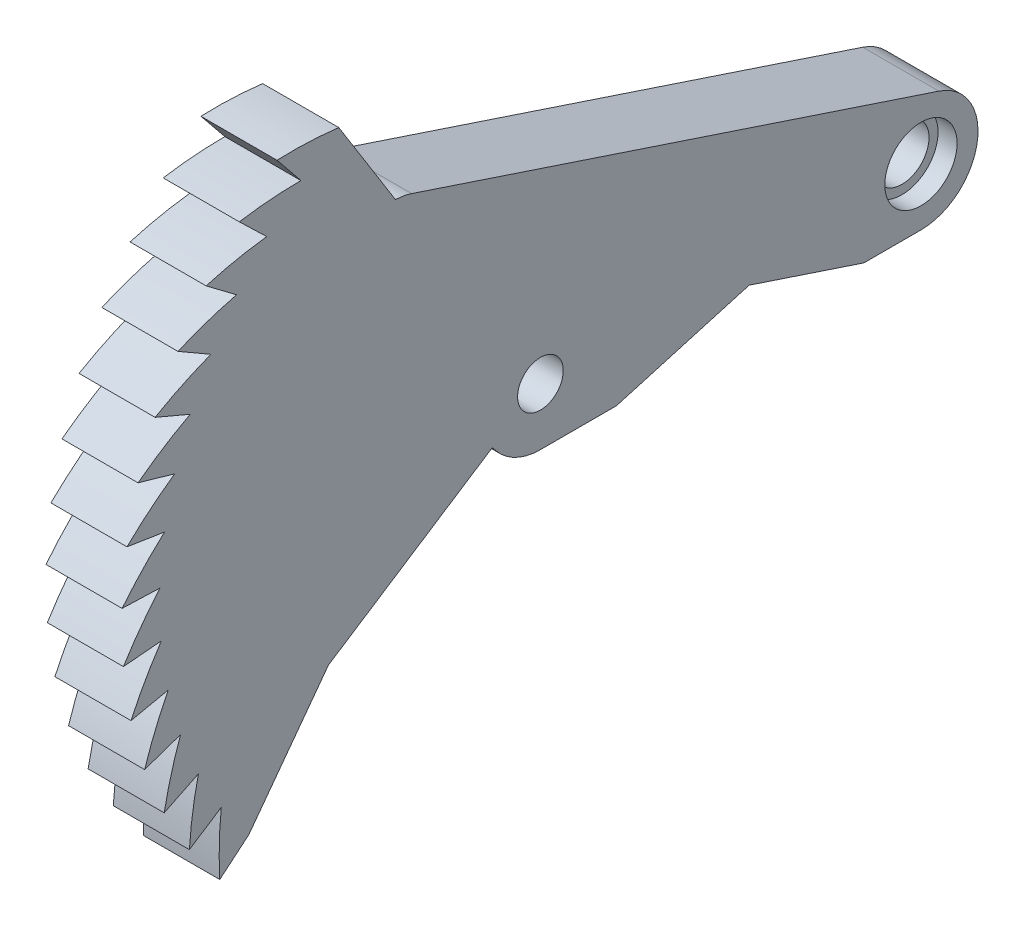
from build123d import *

# Parameters (mm, degrees)
SKETCH_1_R               = 1.2
SKETCH_1_R_2             = 1.425
EXTRUDE_1_DEPTH          = 2
SKETCH_3_R               = 1.9
CUT_EXTRUDE_2_DEPTH      = 1
EXTRUDE_2_DEPTH          = 2
EXTRUDE_3_DEPTH          = 2
PATTERN_CIRCULAR_1_COUNT = 13
PATTERN_CIRCULAR_1_ANGLE = 84
PATTERN_CIRCULAR_2_COUNT = 2
PATTERN_CIRCULAR_2_ANGLE = 7
SKETCH_1_2_R             = 1.2
CUT_EXTRUDE_3_DEPTH      = 2
CUT_EXTRUDE_4_DEPTH      = 3
CUT_EXTRUDE_4_DEPTH_BACK = 3


with BuildPart() as part:
    # 草图1 → 凸台-拉伸1 (new body, symmetric)
    with BuildSketch(Plane(origin=(0, 0, 0), x_dir=(0, 0, -1), z_dir=(1, 0, 0))):
        with BuildLine():
            Line((0, -3), (20, -3))
            ThreePointArc((20, -3), (22.961615091, -0.478368116), (20.944494821, 2.84744263))
            Line((20.944494821, 2.84744263), (-6.768956495, 12.039975948))
            ThreePointArc((-6.768956495, 12.039975948), (-10.195419033, 10.877714688), (-10.011584646, 7.264170488))
            Line((-10.011584646, 7.264170488), (-2.298133329, -1.928362829))
            ThreePointArc((-2.298133329, -1.928362829), (-1.267854785, -2.718923361), (0, -3))
        make_face()
        Circle(SKETCH_1_R, mode=Mode.SUBTRACT)
        with Locations((20, 0)):
            Circle(SKETCH_1_R_2, mode=Mode.SUBTRACT)
        with Locations((-7.713451316, 9.192533317)):
            Circle(SKETCH_1_R, mode=Mode.SUBTRACT)
    extrude(amount=EXTRUDE_1_DEPTH, both=True)

    # 草图3 → 切除-拉伸2 (cut)
    with BuildSketch(Plane(origin=(2, 0, 0), x_dir=(0, 0, -1), z_dir=(1, 0, 0))):
        with Locations((20, 0)):
            Circle(SKETCH_3_R)
    extrude(amount=-CUT_EXTRUDE_2_DEPTH, mode=Mode.SUBTRACT)

    # 草图4 → 凸台-拉伸2 (add, symmetric)
    with BuildSketch(Plane(origin=(0, 0, 0), x_dir=(0, 0, -1), z_dir=(1, 0, 0))):
        with BuildLine():
            Line((-11.14507328, -7.237695215), (0, 0))
            Line((0, 0), (-10.598385285, 16.960961923))
            ThreePointArc((-10.598385285, 16.960961923), (-19.753766812, 3.128689301), (-15.320888862, -12.855752194))
            Line((-15.320888862, -12.855752194), (-11.14507328, -7.237695215))
        make_face()
    extrude(amount=EXTRUDE_2_DEPTH, both=True)

    # 草图4<3> → 凸台-拉伸3 (add, symmetric)
    with BuildSketch(Plane(origin=(0, 0, 0), x_dir=(0, 0, -1), z_dir=(1, 0, 0))):
        with BuildLine():
            Line((-18.450752495, -11.98205877), (-16.773411359, -10.8927807))
            ThreePointArc((-16.773411359, -10.8927807), (-17.407113919, -9.848471202), (-17.975880926, -8.767422936))
            ThreePointArc((-17.975880926, -8.767422936), (-18.278712452, -10.365080481), (-18.450752495, -11.98205877))
        make_face()
    extrude_3 = extrude(amount=EXTRUDE_3_DEPTH, both=True)

    # 阵列(圆周)1: 凸台-拉伸3 ×13 about axis
    pattern_circular_1_axis = Axis((0, 0, 0), (-1, 0, 0))
    for i in range(1, PATTERN_CIRCULAR_1_COUNT):
        add(extrude_3.rotate(pattern_circular_1_axis, i * PATTERN_CIRCULAR_1_ANGLE / (PATTERN_CIRCULAR_1_COUNT - 1)))

    # 阵列(圆周)2: 凸台-拉伸3 ×2 about axis
    pattern_circular_2_axis = Axis((0, 0, 0), (1, 0, 0))
    for i in range(1, PATTERN_CIRCULAR_2_COUNT):
        add(extrude_3.rotate(pattern_circular_2_axis, i * PATTERN_CIRCULAR_2_ANGLE / (PATTERN_CIRCULAR_2_COUNT - 1)))

    # 草图1<2> → 切除-拉伸3 (cut, symmetric)
    with BuildSketch(Plane(origin=(0, 0, 0), x_dir=(0, 0, -1), z_dir=(1, 0, 0))):
        Circle(SKETCH_1_2_R)
    extrude(amount=CUT_EXTRUDE_3_DEPTH, both=True, mode=Mode.SUBTRACT)

    # 草图5 → 切除-拉伸4 (cut, two sides)
    with BuildSketch(Plane(origin=(0, 0, 0), x_dir=(0, 0, -1), z_dir=(1, 0, 0))) as cut_extrude_4_sk:
        Polygon((4, -3), (10.970443107, -1), (17, -3), align=None)
    extrude(amount=CUT_EXTRUDE_4_DEPTH, mode=Mode.SUBTRACT)
    extrude(cut_extrude_4_sk.sketch, amount=-CUT_EXTRUDE_4_DEPTH_BACK, mode=Mode.SUBTRACT)


solid = part.part
